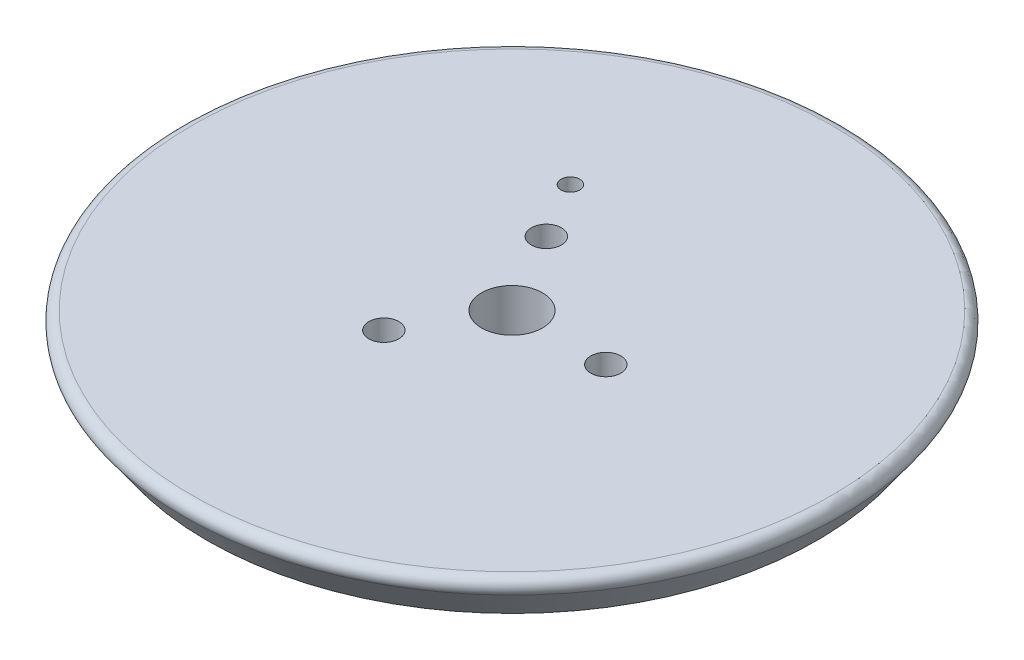
from build123d import *

# Parameters (mm, degrees)
CONG_1_R                = 1
ENL_V_MAT_EXTRU_1_REACH = 10.4
ESQUISSE2_R             = 3.25
ESQUISSE2_R_2           = 1.6
ESQUISSE2_R_3           = 1


with BuildPart() as part:
    # Esquisse1 → Révolution1 (revolve)
    with BuildSketch(Plane.XY):
        Polygon((0, 0), (36.071734624, 0), (32.5, -5), (15, -5), (15, -6.4), (5.25, -6.4), (3.25, -8.4), (0, -8.4), align=None)
    revolve(axis=Axis((0, 33.166287016, 0), (0, -1, 0)))

    # Congé1
    cong_1_edges = [part.edges().sort_by_distance(p)[0] for p in [
        (-36.071734624, 0, 0),
    ]]
    fillet(cong_1_edges, radius=CONG_1_R)

    # Esquisse2 → Enlèv. mat.-Extru.1 (cut, up to next)
    with BuildSketch(Plane(origin=(0, 0, 0), x_dir=(1, 0, 0), z_dir=(0, 1, 0)), mode=Mode.PRIVATE) as enl_v_mat_extru_1_sk1:
        Circle(ESQUISSE2_R)
    enl_v_mat_extru_1_tool1 = extrude(enl_v_mat_extru_1_sk1.sketch, amount=-ENL_V_MAT_EXTRU_1_REACH, mode=Mode.PRIVATE) & part.part
    add(enl_v_mat_extru_1_tool1.solids().sort_by_distance((0, 0, 0))[0], mode=Mode.SUBTRACT)
    # Esquisse2 → Enlèv. mat.-Extru.1 (cut, up to next)
    with BuildSketch(Plane(origin=(0, 0, 0), x_dir=(1, 0, 0), z_dir=(0, 1, 0)), mode=Mode.PRIVATE) as enl_v_mat_extru_1_sk2:
        with Locations((10, 0)):
            Circle(ESQUISSE2_R_2)
    enl_v_mat_extru_1_tool2 = extrude(enl_v_mat_extru_1_sk2.sketch, amount=-ENL_V_MAT_EXTRU_1_REACH, mode=Mode.PRIVATE) & part.part
    add(enl_v_mat_extru_1_tool2.solids().sort_by_distance((10, 0, 0))[0], mode=Mode.SUBTRACT)
    # Esquisse2 → Enlèv. mat.-Extru.1 (cut, up to next)
    with BuildSketch(Plane(origin=(0, 0, 0), x_dir=(1, 0, 0), z_dir=(0, 1, 0)), mode=Mode.PRIVATE) as enl_v_mat_extru_1_sk3:
        with Locations((-5, -8.660254038)):
            Circle(ESQUISSE2_R_2)
    enl_v_mat_extru_1_tool3 = extrude(enl_v_mat_extru_1_sk3.sketch, amount=-ENL_V_MAT_EXTRU_1_REACH, mode=Mode.PRIVATE) & part.part
    add(enl_v_mat_extru_1_tool3.solids().sort_by_distance((-5, 0, 8.660254))[0], mode=Mode.SUBTRACT)
    # Esquisse2 → Enlèv. mat.-Extru.1 (cut, up to next)
    with BuildSketch(Plane(origin=(0, 0, 0), x_dir=(1, 0, 0), z_dir=(0, 1, 0)), mode=Mode.PRIVATE) as enl_v_mat_extru_1_sk4:
        with Locations((-5, 8.660254038)):
            Circle(ESQUISSE2_R_2)
    enl_v_mat_extru_1_tool4 = extrude(enl_v_mat_extru_1_sk4.sketch, amount=-ENL_V_MAT_EXTRU_1_REACH, mode=Mode.PRIVATE) & part.part
    add(enl_v_mat_extru_1_tool4.solids().sort_by_distance((-5, 0, -8.660254))[0], mode=Mode.SUBTRACT)
    # Esquisse2 → Enlèv. mat.-Extru.1 (cut, up to next)
    with BuildSketch(Plane(origin=(0, 0, 0), x_dir=(1, 0, 0), z_dir=(0, 1, 0)), mode=Mode.PRIVATE) as enl_v_mat_extru_1_sk5:
        with Locations((-8.5, 14.722431864)):
            Circle(ESQUISSE2_R_3)
    enl_v_mat_extru_1_tool5 = extrude(enl_v_mat_extru_1_sk5.sketch, amount=-ENL_V_MAT_EXTRU_1_REACH, mode=Mode.PRIVATE) & part.part
    add(enl_v_mat_extru_1_tool5.solids().sort_by_distance((-8.5, 0, -14.722432))[0], mode=Mode.SUBTRACT)


solid = part.part
